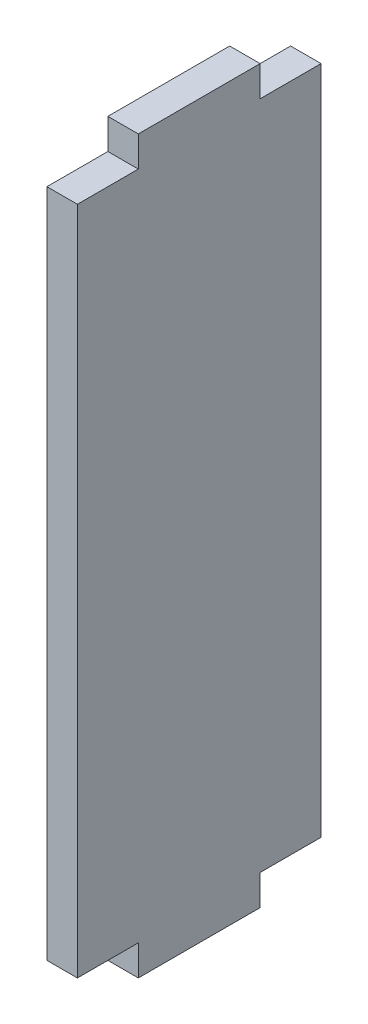
from build123d import *

# Parameters (mm, degrees)
BOSS_EXTRUDE1_DEPTH = 5


with BuildPart() as part:
    # Sketch1 → Boss-Extrude1 (new body)
    with BuildSketch(Plane(origin=(0, 0, 0), x_dir=(0, 0, -1), z_dir=(1, 0, 0))):
        Polygon((-20, 45), (-10, 45), (-10, 50), (10, 50), (10, 45), (20, 45), (20, -65), (10, -65), (10, -70), (-10, -70), (-10, -65), (-20, -65), align=None)
    extrude(amount=BOSS_EXTRUDE1_DEPTH)


solid = part.part
